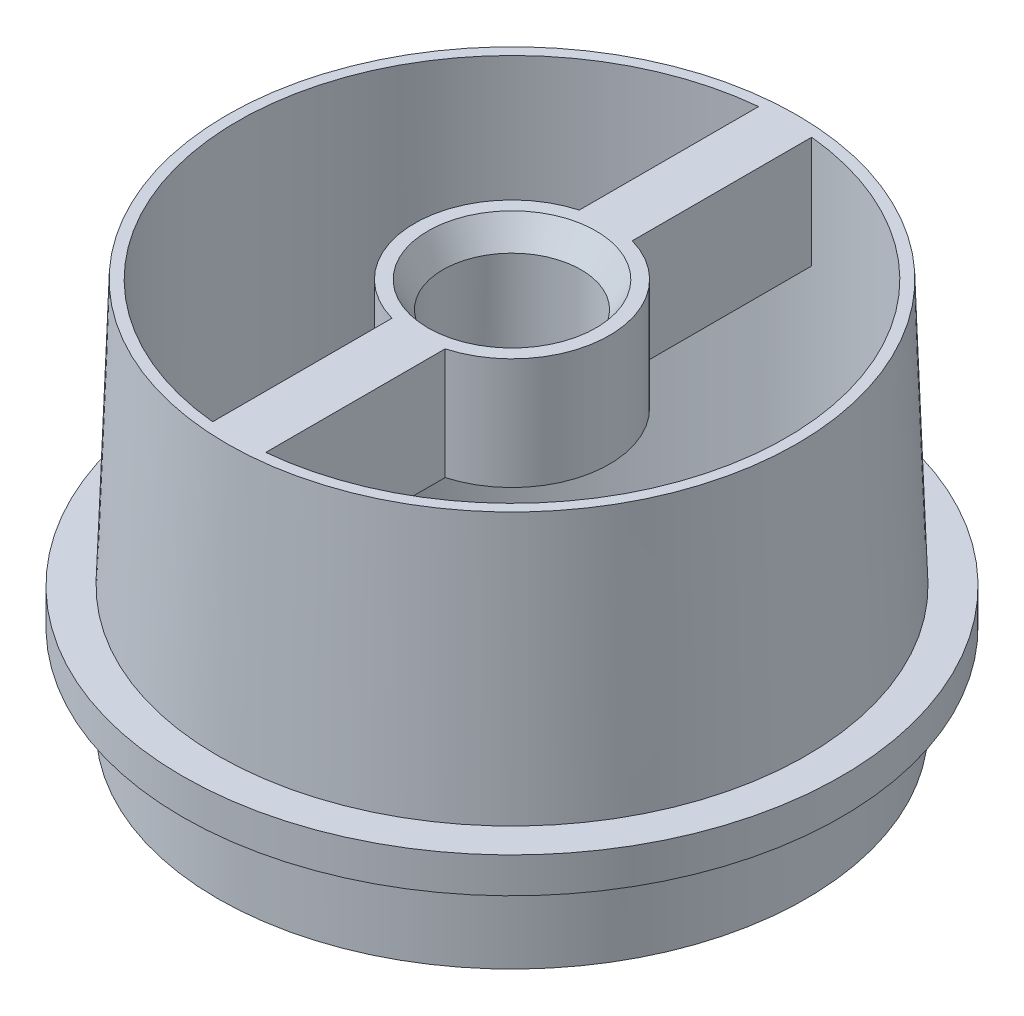
from build123d import *

# Parameters (mm, degrees)
SKETCH1_R           = 16.625
SKETCH1_R_2         = 15.5
BOSS_EXTRUDE1_DEPTH = 15
BOSS_EXTRUDE1_DRAFT = 2
SKETCH4_R           = 18.625
SKETCH4_R_2         = 15.5
BOSS_EXTRUDE2_DEPTH = 2
SKETCH5_R           = 16.625
SKETCH5_R_2         = 15.5
BOSS_EXTRUDE3_DEPTH = 5
SKETCH9_R           = 16.101188458
SKETCH9_R_2         = 15.5
BOSS_EXTRUDE5_DEPTH = 15
BOSS_EXTRUDE8_DEPTH = 6.3
SKETCH11_R          = 3.9
CUT_EXTRUDE2_DEPTH  = 35.318817724


with BuildPart() as part:
    # Sketch1 → Boss-Extrude1 (with draft: the straight prism first)
    with BuildSketch(Plane(origin=(0, 0, 0), x_dir=(1, 0, 0), z_dir=(0, 1, 0))):
        Circle(SKETCH1_R)
        Circle(SKETCH1_R_2, mode=Mode.SUBTRACT)
    extrude(amount=BOSS_EXTRUDE1_DEPTH)
    # Boss-Extrude1: the draft: its side faces are tilted about the plane it starts from
    boss_extrude1_sides = [part.faces().sort_by_distance(p)[0] for p in [
        (-16.625, 7.5, 0),
        (-15.5, 7.5, 0),
    ]]
    draft(boss_extrude1_sides, Plane(origin=(0, 0, 0), x_dir=(1, 0, 0), z_dir=(0, 1, 0)), BOSS_EXTRUDE1_DRAFT)

    # Sketch4 → Boss-Extrude2 (add)
    with BuildSketch(Plane(origin=(0, 0, 0), x_dir=(1, 0, 0), z_dir=(0, 1, 0))):
        with Locations(Location((0, 0, 0), (0, 0, 270))):
            Circle(SKETCH4_R)
        with Locations(Location((0, 0, 0), (0, 0, 270))):
            Circle(SKETCH4_R_2, mode=Mode.SUBTRACT)
    extrude(amount=-BOSS_EXTRUDE2_DEPTH)

    # Sketch5 → Boss-Extrude3 (add)
    with BuildSketch(Plane.XZ.offset(2)):
        with Locations(Location((0, 0, 0), (0, 0, 90))):
            Circle(SKETCH5_R)
        with Locations(Location((0, 0, 0), (0, 0, 90))):
            Circle(SKETCH5_R_2, mode=Mode.SUBTRACT)
    extrude(amount=BOSS_EXTRUDE3_DEPTH)

    # Sketch9 → Boss-Extrude5 (add, through all)
    with BuildSketch(Plane(origin=(0, 0, 0), x_dir=(1, 0, 0), z_dir=(0, 1, 0))):
        Circle(SKETCH9_R)
        with Locations(Location((0, 0, 0), (0, 0, 270))):
            Circle(SKETCH9_R_2, mode=Mode.SUBTRACT)
    extrude(amount=BOSS_EXTRUDE5_DEPTH)

    # Sketch10 → Boss-Extrude8 (add)
    with BuildSketch(Plane(origin=(0, 15, 0), x_dir=(1, 0, 0), z_dir=(0, 1, 0))):
        with BuildLine():
            Line((-1.490883565, 5.294078409), (-1.490883565, 15.428132298))
            ThreePointArc((-1.490883565, 15.428132298), (0.009159426, 15.499997294), (1.509116435, 15.426359505))
            Line((1.509116435, 15.426359505), (1.509116435, 5.288909867))
            ThreePointArc((1.509116435, 5.288909867), (5.5, 0), (1.509116435, -5.288909867))
            Line((1.509116435, -5.288909867), (1.509116435, -15.426359505))
            ThreePointArc((1.509116435, -15.426359505), (0.009159426, -15.499997294), (-1.490883565, -15.428132298))
            Line((-1.490883565, -15.428132298), (-1.490883565, -5.294078409))
            ThreePointArc((-1.490883565, -5.294078409), (-5.5, 0), (-1.490883565, 5.294078409))
        make_face()
    extrude(amount=-BOSS_EXTRUDE8_DEPTH)

    # Sketch11 → Cut-Extrude2 (cut, through all)
    with BuildSketch(Plane(origin=(0, 15, 0), x_dir=(1, 0, 0), z_dir=(0, 1, 0))):
        with Locations(Location((0, 0, 0), (0, 0, 270))):
            Circle(SKETCH11_R)
    extrude(amount=-CUT_EXTRUDE2_DEPTH, mode=Mode.SUBTRACT)

    # Cut-Extrude3 cone 1 section (through the dimple's axis) → Cut-Extrude3 (revolve, cut)
    with BuildSketch(Plane(origin=(0, 15, 0), x_dir=(0, 0, 1), z_dir=(1, 0, 0))):
        Polygon((0, 0), (4.75, 0), (0, 8.227241336), align=None)
    revolve(axis=Axis((0, 15, 0), (0, -1, 0)), mode=Mode.SUBTRACT)


solid = part.part
